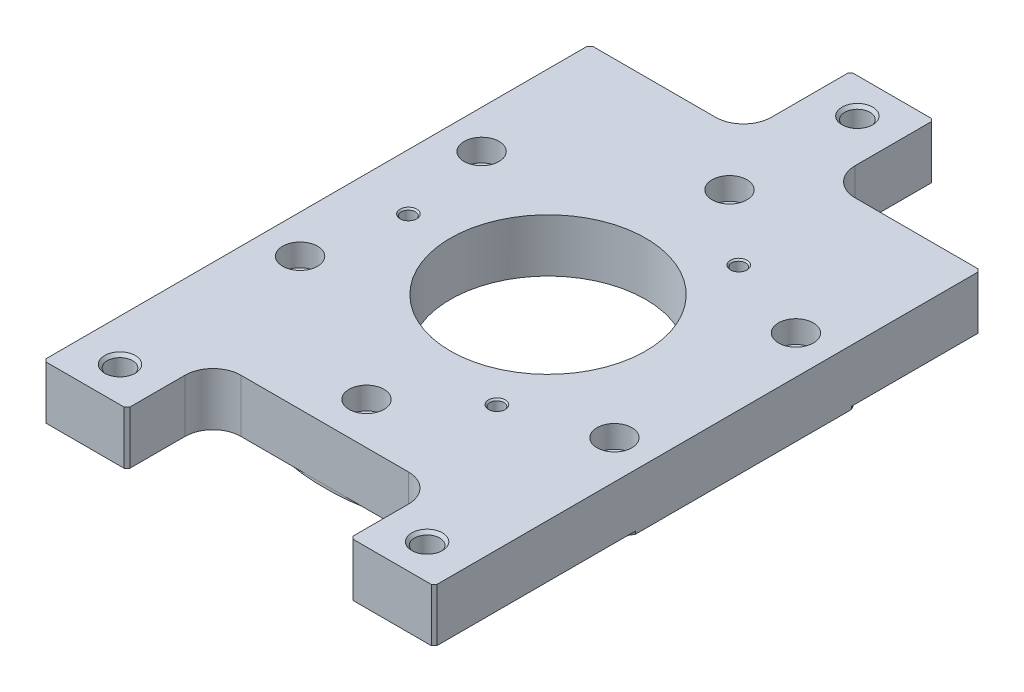
from build123d import *

# Parameters (mm, degrees)
SKETCH1_W                                     = 177.8
SKETCH1_H                                     = 311.15
EXTRUDE1_DEPTH                                = 25.4
CBORE_FOR_3_8_SOCKET_HEAD_CAP_SCREW1_AT_COUNT = 2
CBORE_FOR_3_8_SOCKET_HEAD_CAP_SCREW1_AT_PITCH = 142.980794165
CBORE_FOR_3_8_SOCKET_HEAD_CAP_SCREW1_2_COUNT  = 2
CBORE_FOR_3_8_SOCKET_HEAD_CAP_SCREW1_2_PITCH  = 82.55
CBORE_FOR_3_8_SOCKET_HEAD_CAP_SCREW1_3_COUNT  = 2
CBORE_FOR_3_8_SOCKET_HEAD_CAP_SCREW1_3_PITCH  = 142.980794165
CBORE_FOR_3_8_SOCKET_HEAD_CAP_SCREW1_4_COUNT  = 2
CBORE_FOR_3_8_SOCKET_HEAD_CAP_SCREW1_4_PITCH  = 165.1
CBORE_FOR_3_8_SOCKET_HEAD_CAP_SCREW1_5_COUNT  = 2
CBORE_FOR_3_8_SOCKET_HEAD_CAP_SCREW1_5_PITCH  = 82.55
SKETCH4_R                                     = 44.45
CUT_EXTRUDE1_DEPTH                            = 26.4
SKETCH8_R                                     = 63.5
CUT_EXTRUDE4_DEPTH                            = 1.27
SKETCH9_R                                     = 181.94716953
SKETCH9_R_2                                   = 101.6
CUT_EXTRUDE5_DEPTH                            = 1.27
F_1_4_20_TAPPED_HOLE1_AT_2_COUNT              = 2
F_1_4_20_TAPPED_HOLE1_AT_2_PITCH              = 109.985226281
F_1_4_20_TAPPED_HOLE1_AT_3_COUNT              = 2
F_1_4_20_TAPPED_HOLE1_AT_3_PITCH              = 109.985226281
SKETCH18_W                                    = 69.85
SKETCH18_H                                    = 50.8
SKETCH18_W_2                                  = 101.6
CUT_EXTRUDE7_DEPTH                            = 26.4
SKETCH19_W                                    = 38.1
SKETCH19_H                                    = 2.159
SKETCH19_W_2                                  = 177.8
SKETCH19_H_2                                  = 11.684
CUT_EXTRUDE8_DEPTH                            = 26.4
F_1_2_20_TAPPED_HOLE1_AT_2_COUNT              = 2
F_1_2_20_TAPPED_HOLE1_AT_2_PITCH              = 274.589771749
F_1_2_20_TAPPED_HOLE1_AT_3_COUNT              = 2
F_1_2_20_TAPPED_HOLE1_AT_3_PITCH              = 274.589771749
FILLET2_R                                     = 12.7
CHAMFER1_SIZE                                 = 1.27


with BuildPart() as part:
    # Sketch1 → Extrude1 (new body)
    with BuildSketch(Plane(origin=(0, 0, 0), x_dir=(1, 0, 0), z_dir=(0, 1, 0))):
        with Locations((0, 3.175)):
            Rectangle(SKETCH1_W, SKETCH1_H)
    extrude(amount=EXTRUDE1_DEPTH)

    # Sketch2 → CBORE for 3_8 Socket Head Cap Screw1 (revolve, cut)
    with BuildSketch(Plane(origin=(-71.490397082, 25.4, -41.275), x_dir=(0, 0, 1), z_dir=(1, 0, 0))):
        Polygon((0, 0), (0, 25.4), (5.715, 25.4), (5.15874, 24.76009607), (5.15874, 10.16), (7.9375, 10.16), (7.9375, 0), align=None)
    cbore_for_3_8_socket_head_cap_screw1 = revolve(axis=Axis((-71.490397082, 31.75, -41.275), (0, -1, 0)), mode=Mode.SUBTRACT)

    # CBORE for 3_8 Socket Head Cap Screw1 at: CBORE for 3_8 Socket Head Cap Screw1 ×2
    with Locations(*[Vector(0.5, 0, 0.866025404) * (i * CBORE_FOR_3_8_SOCKET_HEAD_CAP_SCREW1_AT_PITCH) for i in range(1, CBORE_FOR_3_8_SOCKET_HEAD_CAP_SCREW1_AT_COUNT)]):
        add(cbore_for_3_8_socket_head_cap_screw1, mode=Mode.SUBTRACT)

    # CBORE for 3_8 Socket Head Cap Screw1 2: CBORE for 3_8 Socket Head Cap Screw1 ×2
    with Locations(*[Vector(0.866025404, 0, -0.5) * (i * CBORE_FOR_3_8_SOCKET_HEAD_CAP_SCREW1_2_PITCH) for i in range(1, CBORE_FOR_3_8_SOCKET_HEAD_CAP_SCREW1_2_COUNT)]):
        add(cbore_for_3_8_socket_head_cap_screw1, mode=Mode.SUBTRACT)

    # CBORE for 3_8 Socket Head Cap Screw1 3: CBORE for 3_8 Socket Head Cap Screw1 ×2
    with Locations(*[(i * CBORE_FOR_3_8_SOCKET_HEAD_CAP_SCREW1_3_PITCH, 0, 0) for i in range(1, CBORE_FOR_3_8_SOCKET_HEAD_CAP_SCREW1_3_COUNT)]):
        add(cbore_for_3_8_socket_head_cap_screw1, mode=Mode.SUBTRACT)

    # CBORE for 3_8 Socket Head Cap Screw1 4: CBORE for 3_8 Socket Head Cap Screw1 ×2
    with Locations(*[Vector(0.866025404, 0, 0.5) * (i * CBORE_FOR_3_8_SOCKET_HEAD_CAP_SCREW1_4_PITCH) for i in range(1, CBORE_FOR_3_8_SOCKET_HEAD_CAP_SCREW1_4_COUNT)]):
        add(cbore_for_3_8_socket_head_cap_screw1, mode=Mode.SUBTRACT)

    # CBORE for 3_8 Socket Head Cap Screw1 5: CBORE for 3_8 Socket Head Cap Screw1 ×2
    with Locations(*[(0, 0, i * CBORE_FOR_3_8_SOCKET_HEAD_CAP_SCREW1_5_PITCH) for i in range(1, CBORE_FOR_3_8_SOCKET_HEAD_CAP_SCREW1_5_COUNT)]):
        add(cbore_for_3_8_socket_head_cap_screw1, mode=Mode.SUBTRACT)

    # Sketch4 → Cut-Extrude1 (cut, through all)
    with BuildSketch(Plane(origin=(0, 25.4, 0), x_dir=(1, 0, 0), z_dir=(0, 1, 0))):
        with Locations(Location((0, 0, 0), (0, 0, 270))):  # turned: the seam where the file's is
            Circle(SKETCH4_R)
    extrude(amount=-CUT_EXTRUDE1_DEPTH, mode=Mode.SUBTRACT)

    # Sketch8 → Cut-Extrude4 (cut)
    with BuildSketch(Plane.XZ):
        with Locations(Location((0, 0, 0), (0, 0, 270))):  # turned: the seam where the file's is
            Circle(SKETCH8_R)
    extrude(amount=-CUT_EXTRUDE4_DEPTH, mode=Mode.SUBTRACT)

    # Sketch9 → Cut-Extrude5 (cut)
    with BuildSketch(Plane.XZ):
        Circle(SKETCH9_R)
        Circle(SKETCH9_R_2, mode=Mode.SUBTRACT)
    extrude(amount=-CUT_EXTRUDE5_DEPTH, mode=Mode.SUBTRACT)

    # Sketch10 → 1_4-20 Tapped Hole1 (revolve, cut)
    with BuildSketch(Plane(origin=(-63.5, 25.4, 0), x_dir=(0, 0, 1), z_dir=(1, 0, 0))):
        Polygon((0, 0), (0, 16.51), (2.5527, 16.51), (2.5527, 12.7), (3.175, 12.7), (3.175, 0.730483939), (3.81, 0), align=None)
    f_1_4_20_tapped_hole1 = revolve(axis=Axis((-63.5, 31.75, 0), (0, -1, 0)), mode=Mode.SUBTRACT)

    # 1_4-20 Tapped Hole1 at 2: 1_4-20 Tapped Hole1 ×2
    with Locations(*[Vector(0.866025404, 0, 0.5) * (i * F_1_4_20_TAPPED_HOLE1_AT_2_PITCH) for i in range(1, F_1_4_20_TAPPED_HOLE1_AT_2_COUNT)]):
        add(f_1_4_20_tapped_hole1, mode=Mode.SUBTRACT)

    # 1_4-20 Tapped Hole1 at 3: 1_4-20 Tapped Hole1 ×2
    with Locations(*[Vector(0.866025404, 0, -0.5) * (i * F_1_4_20_TAPPED_HOLE1_AT_3_PITCH) for i in range(1, F_1_4_20_TAPPED_HOLE1_AT_3_COUNT)]):
        add(f_1_4_20_tapped_hole1, mode=Mode.SUBTRACT)

    # Sketch18 → Cut-Extrude7 (cut, through all)
    with BuildSketch(Plane(origin=(0, 25.4, 0), x_dir=(1, 0, 0), z_dir=(0, 1, 0))):
        with Locations((53.975, 133.35)):
            Rectangle(SKETCH18_W, SKETCH18_H)
        with Locations((-53.975, 133.35)):
            Rectangle(SKETCH18_W, SKETCH18_H)
        with Locations((0, -127)):
            Rectangle(SKETCH18_W_2, SKETCH18_H)
    extrude(amount=-CUT_EXTRUDE7_DEPTH, mode=Mode.SUBTRACT)

    # Sketch19 → Cut-Extrude8 (cut, through all)
    with BuildSketch(Plane(origin=(0, 25.4, 0), x_dir=(1, 0, 0), z_dir=(0, 1, 0))):
        with Locations((0, 157.6705)):
            Rectangle(SKETCH19_W, SKETCH19_H)
        with Locations((0, -146.558)):
            Rectangle(SKETCH19_W_2, SKETCH19_H_2)
    extrude(amount=-CUT_EXTRUDE8_DEPTH, mode=Mode.SUBTRACT)

    # Sketch14 → 1_2-20 Tapped Hole1 (revolve, cut)
    with BuildSketch(Plane(origin=(0, 25.4, -140.716), x_dir=(0, 0, 1), z_dir=(1, 0, 0))):
        Polygon((0, 0), (0, 24.13), (6.985, 24.13), (5.75437, 22.714322127), (5.75437, 1.415677873), (6.985, 0), align=None)
    f_1_2_20_tapped_hole1 = revolve(axis=Axis((0, 31.75, -140.716), (0, -1, 0)), mode=Mode.SUBTRACT)

    # 1_2-20 Tapped Hole1 at 2: 1_2-20 Tapped Hole1 ×2
    with Locations(*[Vector(0.254379468, 0, 0.967104486) * (i * F_1_2_20_TAPPED_HOLE1_AT_2_PITCH) for i in range(1, F_1_2_20_TAPPED_HOLE1_AT_2_COUNT)]):
        add(f_1_2_20_tapped_hole1, mode=Mode.SUBTRACT)

    # 1_2-20 Tapped Hole1 at 3: 1_2-20 Tapped Hole1 ×2
    with Locations(*[Vector(-0.254379468, 0, 0.967104486) * (i * F_1_2_20_TAPPED_HOLE1_AT_3_PITCH) for i in range(1, F_1_2_20_TAPPED_HOLE1_AT_3_COUNT)]):
        add(f_1_2_20_tapped_hole1, mode=Mode.SUBTRACT)

    # Fillet2
    fillet2_edges = [part.edges().sort_by_distance(p)[0] for p in [
        (19.05, 13.335, -107.95),
        (-19.05, 13.335, -107.95),
        (-50.8, 13.335, 101.6),
        (50.8, 13.335, 101.6),
    ]]
    fillet(fillet2_edges, radius=FILLET2_R)

    # Chamfer1
    chamfer1_edges = [part.edges().sort_by_distance(p)[0] for p in [
        (88.9, 13.335, -107.95),
        (-88.9, 13.335, -107.95),
        (-19.05, 13.335, -156.591),
        (19.05, 13.335, -156.591),
        (50.8, 13.335, 140.716),
        (-88.9, 13.335, 140.716),
        (-50.8, 13.335, 140.716),
        (88.9, 13.335, 140.716),
    ]]
    chamfer(chamfer1_edges, length=CHAMFER1_SIZE)


solid = part.part
